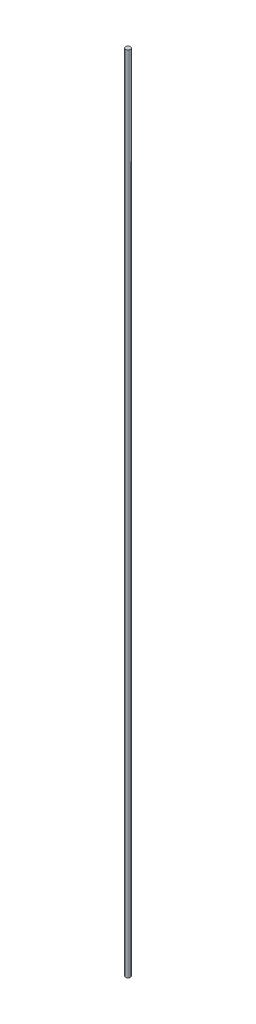
from build123d import *

# Parameters (mm, degrees)
SKETCH1_R           = 4.7625
BOSS_EXTRUDE1_DEPTH = 1600.2


with BuildPart() as part:
    # Sketch1 → Boss-Extrude1 (new body)
    with BuildSketch(Plane(origin=(0, 0, 0), x_dir=(1, 0, 0), z_dir=(0, 1, 0))):
        Circle(SKETCH1_R)
    extrude(amount=BOSS_EXTRUDE1_DEPTH)


solid = part.part
